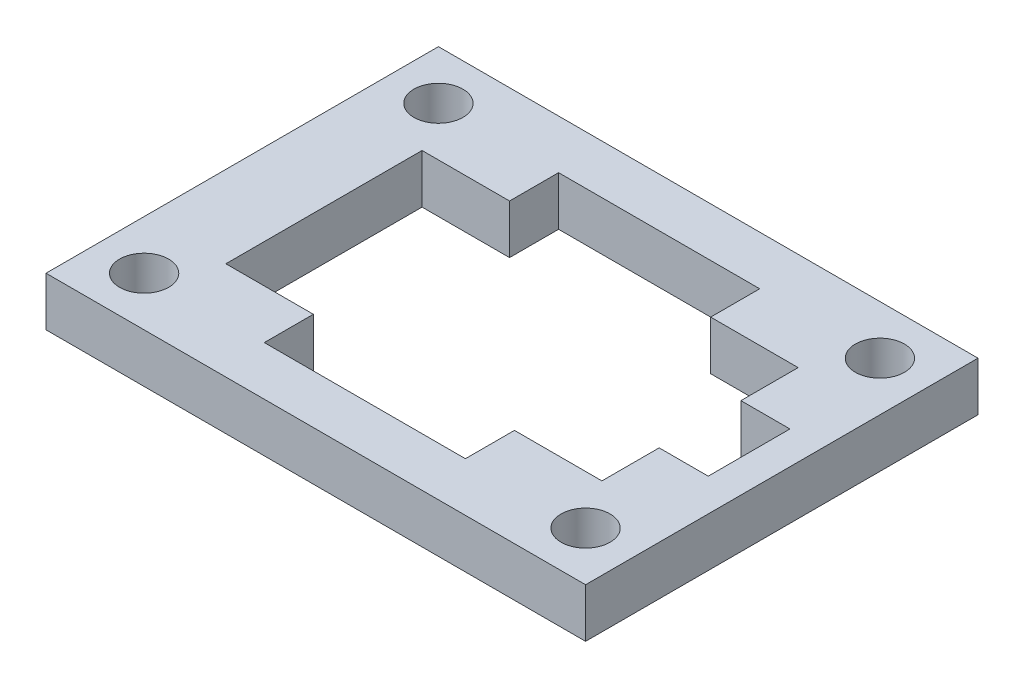
from build123d import *

# Parameters (mm, degrees)
SKETCH1_W           = 33
SKETCH1_H           = 24
BOSS_EXTRUDE1_DEPTH = 3
SKETCH2_W           = 23
SKETCH2_H           = 12
SKETCH2_W_2         = 1.5
SKETCH2_H_2         = 5
SKETCH2_R           = 1.5
SKETCH2_W_3         = 12
SKETCH2_H_3         = 3
CUT_EXTRUDE1_DEPTH  = 4
SKETCH3_W           = 0.15
SKETCH3_H           = 3
SKETCH3_W_2         = 1.5
SKETCH3_H_2         = 5
CUT_EXTRUDE2_DEPTH  = 4


with BuildPart() as part:
    # Sketch1 → Boss-Extrude1 (new body)
    with BuildSketch(Plane(origin=(0, 0, 0), x_dir=(1, 0, 0), z_dir=(0, 1, 0))):
        with Locations((16.5, 12)):
            Rectangle(SKETCH1_W, SKETCH1_H)
    extrude(amount=BOSS_EXTRUDE1_DEPTH)

    # Sketch2 → Cut-Extrude1 (cut, through all)
    with BuildSketch(Plane(origin=(0, 3, 0), x_dir=(1, 0, 0), z_dir=(0, 1, 0))):
        with Locations((16.5, 12)):
            Rectangle(SKETCH2_W, SKETCH2_H)
        with Locations((28.75, 12)):
            Rectangle(SKETCH2_W_2, SKETCH2_H_2)
        with Locations((30, 21)):
            Circle(SKETCH2_R)
        with Locations((16.5, 4.5)):
            Rectangle(SKETCH2_W_3, SKETCH2_H_3)
        with Locations((16.5, 19.5)):
            Rectangle(SKETCH2_W_3, SKETCH2_H_3)
        with Locations((30, 3)):
            Circle(SKETCH2_R)
        with Locations((3, 3)):
            Circle(SKETCH2_R)
        with Locations((3, 21)):
            Circle(SKETCH2_R)
    extrude(amount=-CUT_EXTRUDE1_DEPTH, mode=Mode.SUBTRACT)

    # Sketch3 → Cut-Extrude2 (cut, through all)
    with BuildSketch(Plane(origin=(0, 3, 0), x_dir=(1, 0, 0), z_dir=(0, 1, 0))):
        with Locations((10.425, 19.5)):
            Rectangle(SKETCH3_W, SKETCH3_H)
        with Locations((22.575, 19.5)):
            Rectangle(SKETCH3_W, SKETCH3_H)
        with Locations((22.575, 4.5)):
            Rectangle(SKETCH3_W, SKETCH3_H)
        with Locations((10.425, 4.5)):
            Rectangle(SKETCH3_W, SKETCH3_H)
        with Locations((30.25, 12)):
            Rectangle(SKETCH3_W_2, SKETCH3_H_2)
    extrude(amount=-CUT_EXTRUDE2_DEPTH, mode=Mode.SUBTRACT)


solid = part.part
